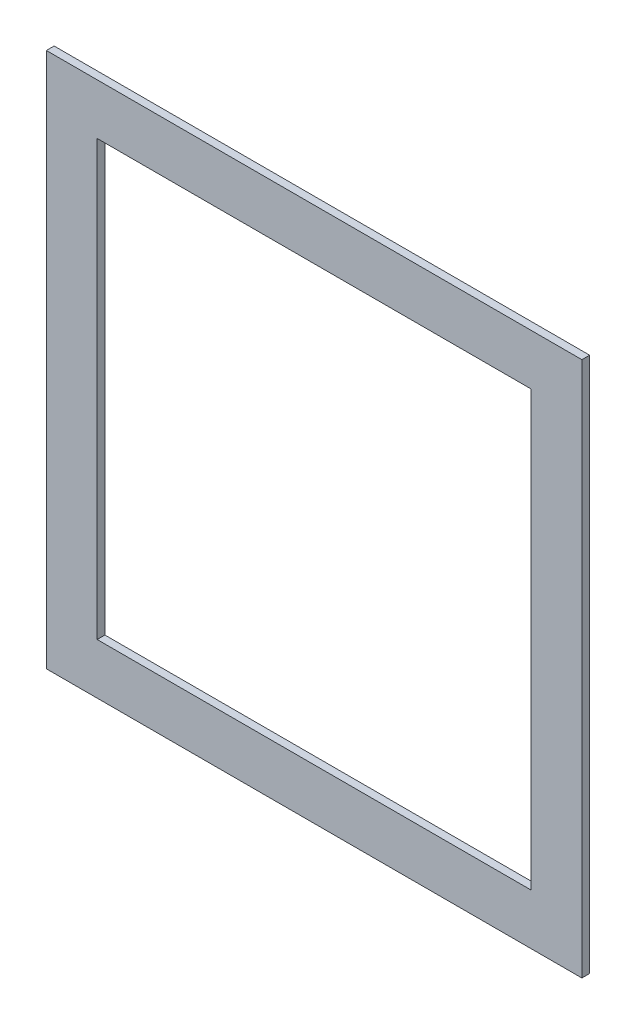
from build123d import *

# Parameters (mm, degrees)
SKETCH1_W           = 368.3
SKETCH1_H           = 368.3
SKETCH1_W_2         = 298.45
SKETCH1_H_2         = 298.45
BOSS_EXTRUDE1_DEPTH = 5.334


with BuildPart() as part:
    # Sketch1 → Boss-Extrude1 (new body)
    with BuildSketch(Plane.XY):
        Rectangle(SKETCH1_W, SKETCH1_H)
        Rectangle(SKETCH1_W_2, SKETCH1_H_2, mode=Mode.SUBTRACT)
    extrude(amount=BOSS_EXTRUDE1_DEPTH)


solid = part.part
